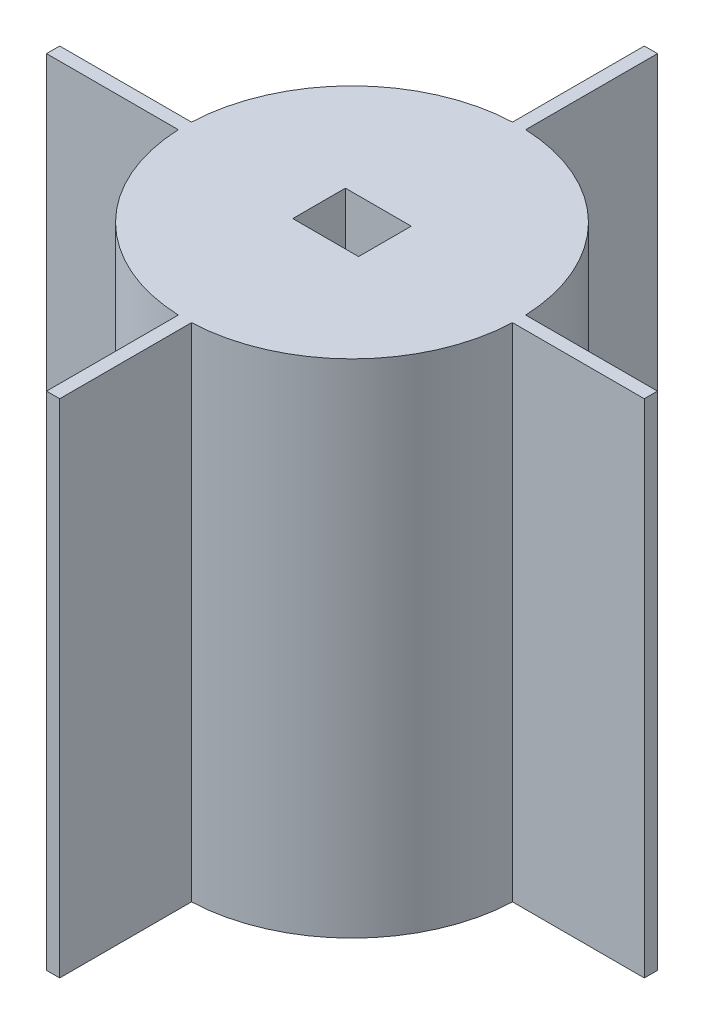
from build123d import *

# Parameters (mm, degrees)
SKETCH1_R           = 12.7
BOSS_EXTRUDE1_DEPTH = 38.1
SKETCH2_W           = 5
SKETCH2_H           = 4.000000128
CUT_EXTRUDE2_DEPTH  = 8
SKETCH5_W           = 1
SKETCH5_H           = 20.2
SKETCH5_W_2         = 20.2
SKETCH5_H_2         = 1
BOSS_EXTRUDE2_DEPTH = 38.1


with BuildPart() as part:
    # Sketch1 → Boss-Extrude1 (new body)
    with BuildSketch(Plane(origin=(0, 0, 0), x_dir=(1, 0, 0), z_dir=(0, 1, 0))):
        Circle(SKETCH1_R)
    extrude(amount=BOSS_EXTRUDE1_DEPTH)

    # Sketch2 → Cut-Extrude2 (cut)
    with BuildSketch(Plane(origin=(0, 38.1, 0), x_dir=(1, 0, 0), z_dir=(0, 1, 0))):
        Rectangle(SKETCH2_W, SKETCH2_H)
    extrude(amount=-CUT_EXTRUDE2_DEPTH, mode=Mode.SUBTRACT)

    # Sketch5 → Boss-Extrude2 (add)
    with BuildSketch(Plane(origin=(0, 38.1, 0), x_dir=(1, 0, 0), z_dir=(0, 1, 0))):
        with Locations((0, 12.6)):
            Rectangle(SKETCH5_W, SKETCH5_H)
        with Locations((-12.6, 0)):
            Rectangle(SKETCH5_W_2, SKETCH5_H_2)
        with Locations((12.6, 0)):
            Rectangle(SKETCH5_W_2, SKETCH5_H_2)
        with Locations((0, -12.6)):
            Rectangle(SKETCH5_W, SKETCH5_H)
    extrude(amount=-BOSS_EXTRUDE2_DEPTH)


solid = part.part
